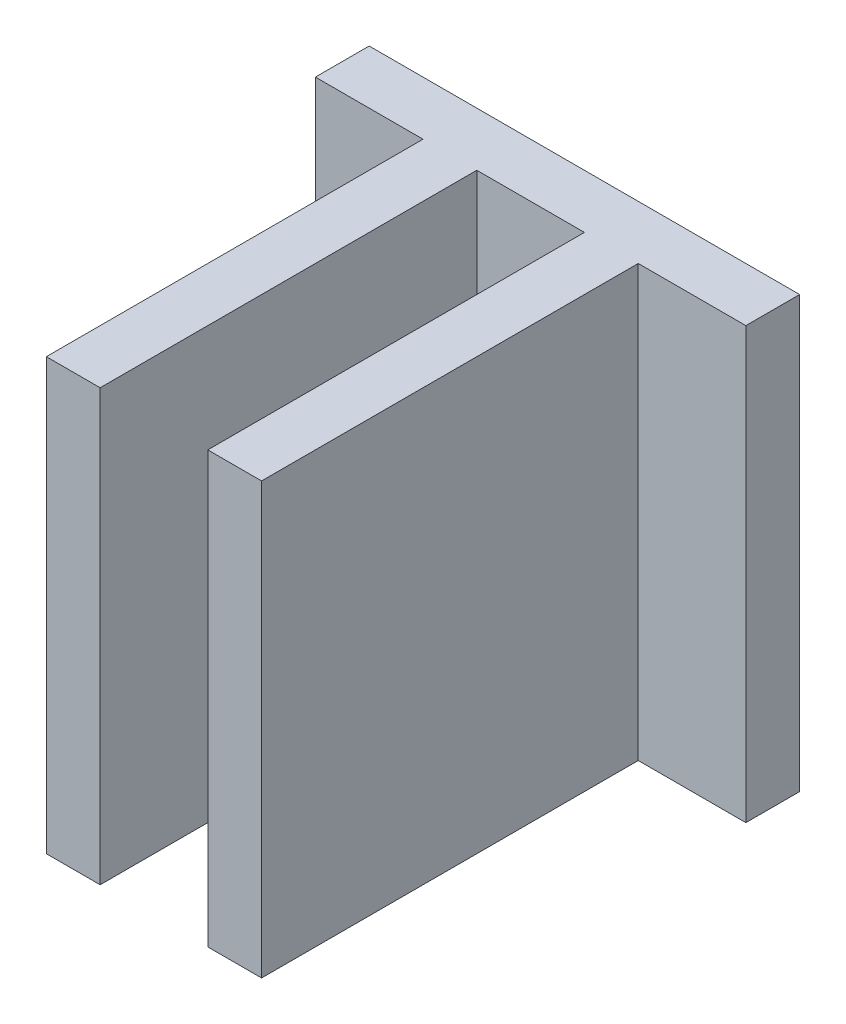
from build123d import *

# Parameters (mm, degrees)
BOSS_EXTRUDE1_DEPTH = 25.4


with BuildPart() as part:
    # Sketch1 → Boss-Extrude1 (new body)
    with BuildSketch(Plane(origin=(0, 0, 0), x_dir=(1, 0, 0), z_dir=(0, 1, 0))):
        Polygon((0, 0), (25.4, 0), (25.4, -3.175), (19.05, -3.175), (19.05, -25.4), (15.875, -25.4), (15.875, -3.175), (9.525, -3.175), (9.525, -25.4), (6.35, -25.4), (6.35, -3.175), (0, -3.175), align=None)
    extrude(amount=BOSS_EXTRUDE1_DEPTH)


solid = part.part
